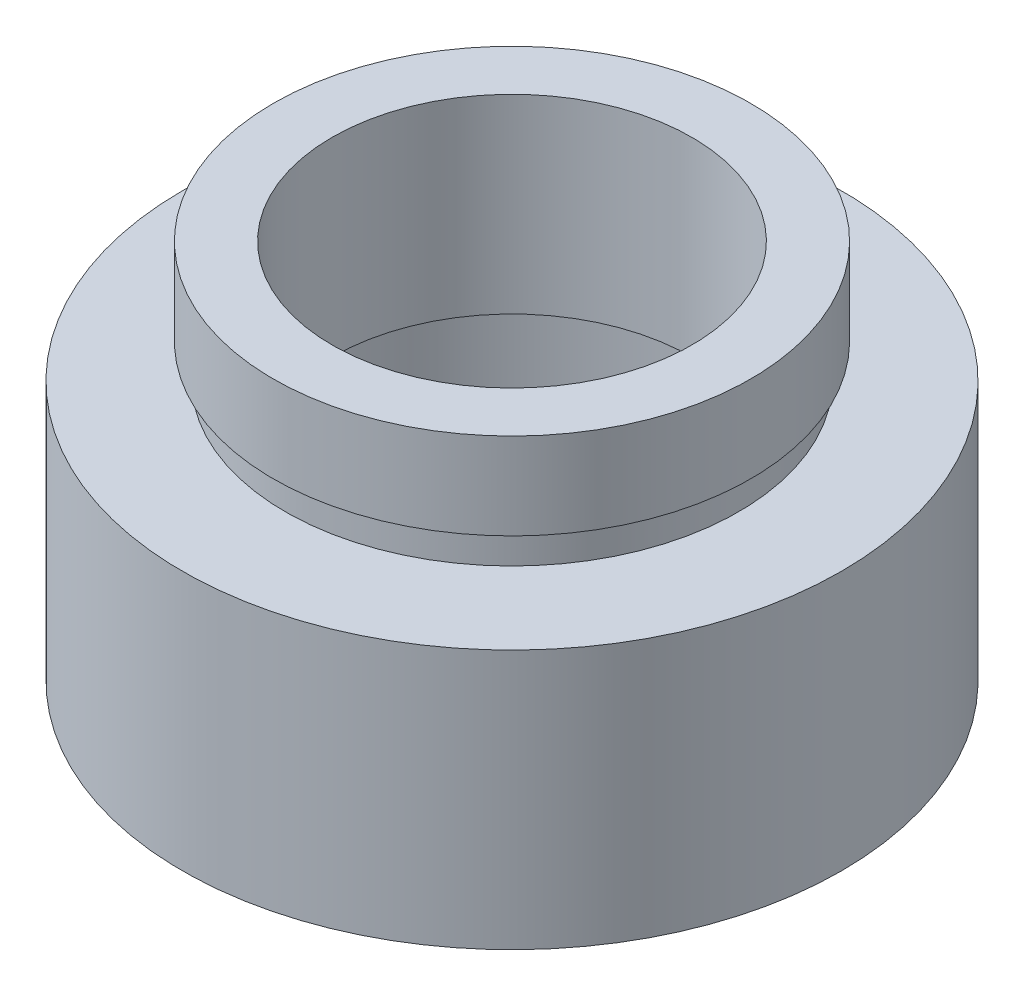
from build123d import *


with BuildPart() as part:
    # 草图1 → 旋转1 (revolve)
    with BuildSketch(Plane.XY, mode=Mode.PRIVATE) as revolve_1_sk:
        Polygon((7, 0), (7, 4.5), (7.6, 4.5), (7.6, 5.5), (5.2, 5.5), (5.2, 11), (6.9, 11), (6.9, 8.5), (6.55, 8.5), (6.55, 7.5), (9.525, 7.5), (9.525, 0), align=None)
    revolve(revolve_1_sk.sketch.rotate(Axis((0, 16.886018237, 0), (0, -1, 0)), 180), axis=Axis((0, 16.886018237, 0), (0, -1, 0)))  # turned: the seam where the file's is


solid = part.part
